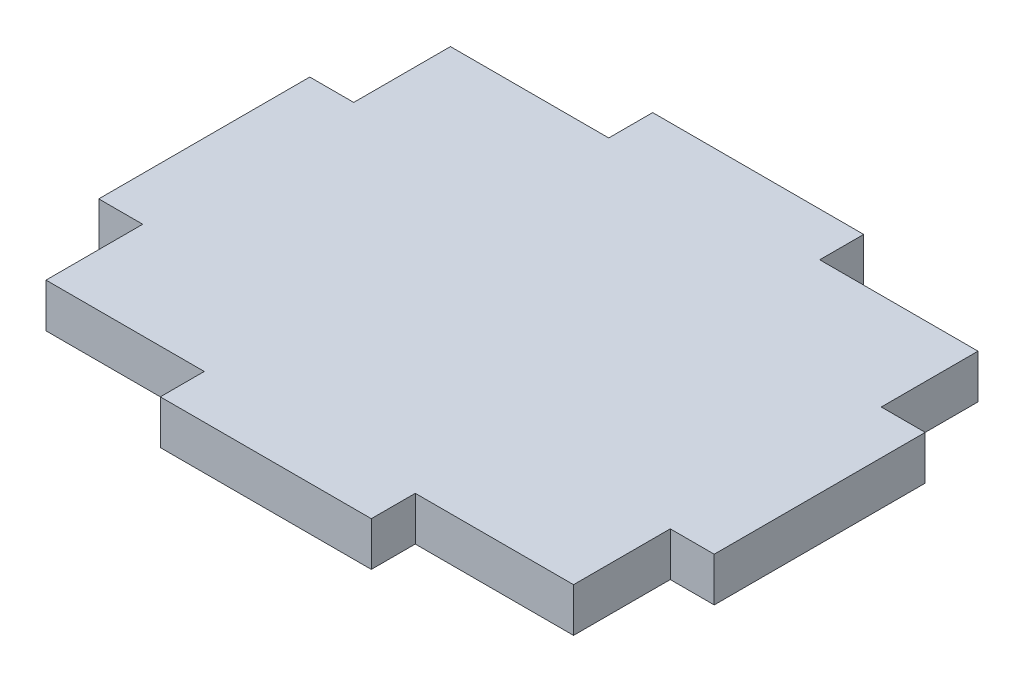
from build123d import *

# Parameters (mm, degrees)
SKETCH1_W           = 76.2
SKETCH1_H           = 58.42
BOSS_EXTRUDE1_DEPTH = 6.35
SKETCH2_W           = 30.48
SKETCH2_H           = 6.35
SKETCH2_W_2         = 6.35
SKETCH2_H_2         = 30.48
BOSS_EXTRUDE2_DEPTH = 6.35


with BuildPart() as part:
    # Sketch1 → Boss-Extrude1 (new body)
    with BuildSketch(Plane(origin=(0, 0, 0), x_dir=(1, 0, 0), z_dir=(0, 1, 0))):
        with Locations((-38.1, -29.21)):
            Rectangle(SKETCH1_W, SKETCH1_H)
    extrude(amount=BOSS_EXTRUDE1_DEPTH)

    # Sketch2 → Boss-Extrude2 (add)
    with BuildSketch(Plane(origin=(0, 6.35, 0), x_dir=(1, 0, 0), z_dir=(0, 1, 0))):
        with Locations((-38.1, -61.595)):
            Rectangle(SKETCH2_W, SKETCH2_H)
        with Locations((-79.375, -29.21)):
            Rectangle(SKETCH2_W_2, SKETCH2_H_2)
        with Locations((-38.1, 3.175)):
            Rectangle(SKETCH2_W, SKETCH2_H)
        with Locations((3.175, -29.21)):
            Rectangle(SKETCH2_W_2, SKETCH2_H_2)
    extrude(amount=-BOSS_EXTRUDE2_DEPTH)


solid = part.part
